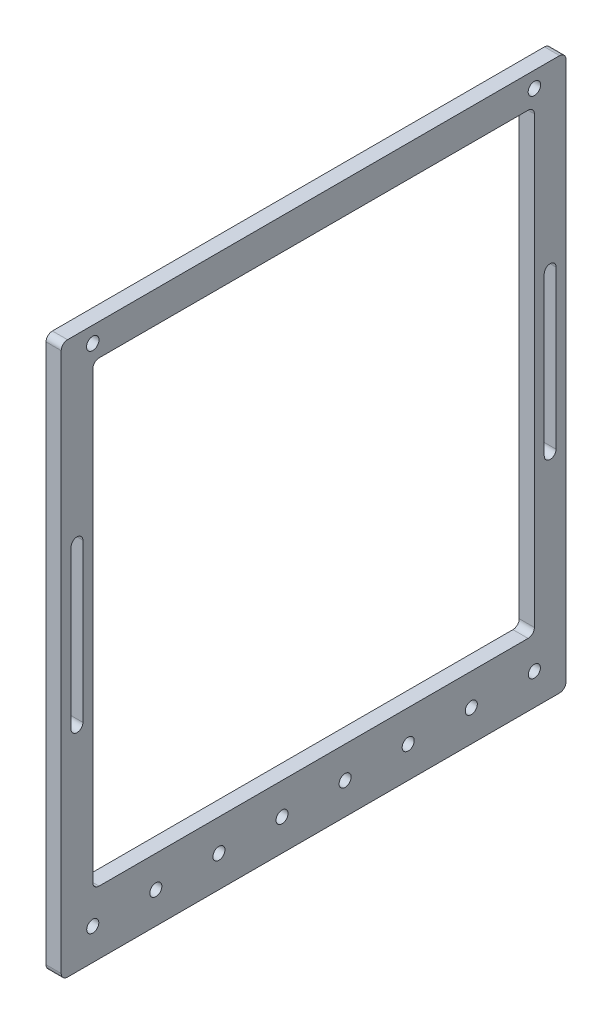
from build123d import *

# Parameters (mm, degrees)
SKETCH1_W               = 203.2
SKETCH1_H               = 222.25
SKETCH1_R               = 2.425
SKETCH1_W_2             = 177.8
SKETCH1_H_2             = 184.15
BOSS_EXTRUDE1_DEPTH     = 6.096
FILLET1_R               = 2.54
CUT_EXTRUDE1_DEPTH      = 7.096
SKETCH3_R               = 2.505
CUT_EXTRUDE2_DEPTH      = 1
CUT_EXTRUDE2_DEPTH_BACK = 7.096


with BuildPart() as part:
    # Sketch1 → Boss-Extrude1 (new body)
    with BuildSketch(Plane(origin=(0, 0, 0), x_dir=(0, 0, -1), z_dir=(1, 0, 0))):
        with Locations((88.9, -98.425)):
            Rectangle(SKETCH1_W, SKETCH1_H)
        with Locations((0, -196.85)):
            Circle(SKETCH1_R, mode=Mode.SUBTRACT)
        with Locations((25.4, -196.85)):
            Circle(SKETCH1_R, mode=Mode.SUBTRACT)
        with Locations((50.8, -196.85)):
            Circle(SKETCH1_R, mode=Mode.SUBTRACT)
        with Locations((76.2, -196.85)):
            Circle(SKETCH1_R, mode=Mode.SUBTRACT)
        with Locations((101.6, -196.85)):
            Circle(SKETCH1_R, mode=Mode.SUBTRACT)
        with Locations((127, -196.85)):
            Circle(SKETCH1_R, mode=Mode.SUBTRACT)
        with Locations((152.4, -196.85)):
            Circle(SKETCH1_R, mode=Mode.SUBTRACT)
        with Locations((177.8, -196.85)):
            Circle(SKETCH1_R, mode=Mode.SUBTRACT)
        with Locations((88.9, -92.075)):
            Rectangle(SKETCH1_W_2, SKETCH1_H_2, mode=Mode.SUBTRACT)
    extrude(amount=BOSS_EXTRUDE1_DEPTH)

    # Fillet1
    fillet1_edges = [part.edges().sort_by_distance(p)[0] for p in [
        (3.048, 0, 0),
        (3.048, -184.15, 0),
        (3.048, -184.15, -177.8),
        (3.048, 0, -177.8),
        (3.048, 12.7, 12.7),
        (3.048, 12.7, -190.5),
        (3.048, -209.55, -190.5),
        (3.048, -209.55, 12.7),
    ]]
    fillet(fillet1_edges, radius=FILLET1_R)

    # Sketch2 → Cut-Extrude1 (cut, through all)
    with BuildSketch(Plane(origin=(6.096, 0, 0), x_dir=(0, 0, -1), z_dir=(1, 0, 0))):
        with BuildLine():
            Line((-3.96875, -60.325), (-3.96875, -123.825))
            ThreePointArc((-3.96875, -123.825), (-6.35, -126.20625), (-8.73125, -123.825))
            Line((-8.73125, -123.825), (-8.73125, -60.325))
            ThreePointArc((-8.73125, -60.325), (-6.35, -57.94375), (-3.96875, -60.325))
        make_face()
        with BuildLine():
            Line((181.76875, -60.325), (181.76875, -123.825))
            ThreePointArc((181.76875, -123.825), (184.15, -126.20625), (186.53125, -123.825))
            Line((186.53125, -123.825), (186.53125, -60.325))
            ThreePointArc((186.53125, -60.325), (184.15, -57.94375), (181.76875, -60.325))
        make_face()
    extrude(amount=-CUT_EXTRUDE1_DEPTH, mode=Mode.SUBTRACT)

    # Sketch3 → Cut-Extrude2 (cut, two sides)
    with BuildSketch(Plane(origin=(6.096, 0, 0), x_dir=(0, 0, -1), z_dir=(1, 0, 0))) as cut_extrude2_sk:
        with Locations((177.8, 6.35)):
            Circle(SKETCH3_R)
        with Locations((0, 6.35)):
            Circle(SKETCH3_R)
    extrude(amount=CUT_EXTRUDE2_DEPTH, mode=Mode.SUBTRACT)
    extrude(cut_extrude2_sk.sketch, amount=-CUT_EXTRUDE2_DEPTH_BACK, mode=Mode.SUBTRACT)


solid = part.part
